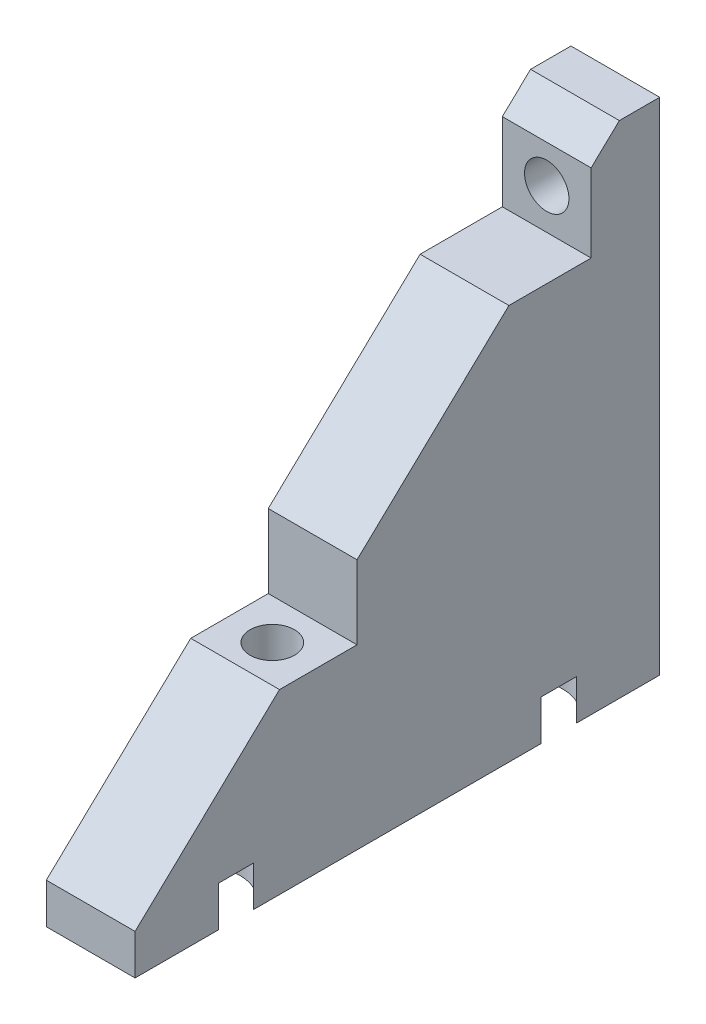
from build123d import *

# Parameters (mm, degrees)
SKETCH1_W           = 65
SKETCH1_H           = 57
BOSS_EXTRUDE1_DEPTH = 5
SKETCH2_W           = 65
SKETCH2_H           = 65
SKETCH2_R           = 2.75
SKETCH2_R_2         = 5
BOSS_EXTRUDE2_DEPTH = 5
SKETCH3_W           = 11
SKETCH3_H           = 60
BOSS_EXTRUDE7_DEPTH = 57
CUT_EXTRUDE2_DEPTH  = 165.705798319
SKETCH6_R           = 2.75
CUT_EXTRUDE3_DEPTH  = 89.911472826
SKETCH7_R           = 2.75
CUT_EXTRUDE4_DEPTH  = 160.515673211
CUT_EXTRUDE5_START  = 57
SKETCH8_W           = 11
SKETCH8_H           = 10
CUT_EXTRUDE5_DEPTH  = 40
CUT_EXTRUDE6_START  = 60
SKETCH9_W           = 11
SKETCH9_H           = 10
CUT_EXTRUDE6_DEPTH  = 56.5
SKETCH10_W          = 7
SKETCH10_H          = 62
SKETCH10_W_2        = 29
CUT_EXTRUDE7_DEPTH  = 160.515673211


with BuildPart() as part:
    # Sketch1 → Boss-Extrude1 (new body)
    with BuildSketch(Plane.XY):
        with Locations((0, -108.5)):
            Rectangle(SKETCH1_W, SKETCH1_H)
    extrude(amount=-BOSS_EXTRUDE1_DEPTH)

    # Sketch2 → Boss-Extrude2 (add)
    with BuildSketch(Plane.XZ.offset(137)):
        with Locations((0, 27.5)):
            Rectangle(SKETCH2_W, SKETCH2_H)
        with Locations(Location((20, 37.5, 0), (0, 0, 270))):
            Circle(SKETCH2_R, mode=Mode.SUBTRACT)
        with Locations(Location((21, 47.5, 0), (0, 0, 270))):
            Circle(SKETCH2_R_2, mode=Mode.SUBTRACT)
        with Locations(Location((-20, 47.5, 0), (0, 0, 270))):
            Circle(SKETCH2_R_2, mode=Mode.SUBTRACT)
        with Locations(Location((-20, 7.5, 0), (0, 0, 90))):
            Circle(SKETCH2_R_2, mode=Mode.SUBTRACT)
        with Locations(Location((21, 7.5, 0), (0, 0, 90))):
            Circle(SKETCH2_R_2, mode=Mode.SUBTRACT)
        with Locations(Location((-20, 37.5, 0), (0, 0, 90))):
            Circle(SKETCH2_R, mode=Mode.SUBTRACT)
    extrude(amount=BOSS_EXTRUDE2_DEPTH)

    # Sketch3 → Boss-Extrude7 (add)
    with BuildSketch(Plane(origin=(0, -137, 0), x_dir=(1, 0, 0), z_dir=(0, 1, 0))):
        with Locations((20, -30)):
            Rectangle(SKETCH3_W, SKETCH3_H)
        with Locations((-20, -30)):
            Rectangle(SKETCH3_W, SKETCH3_H)
    extrude(amount=BOSS_EXTRUDE7_DEPTH)

    # Sketch5 → Cut-Extrude2 (cut, through all)
    with BuildSketch(Plane(origin=(25.5, 0, 0), x_dir=(0, 0, -1), z_dir=(1, 0, 0))):
        Polygon((-60, -137), (0, -80), (-60, -80), align=None)
    extrude(amount=-CUT_EXTRUDE2_DEPTH, mode=Mode.SUBTRACT)

    # Sketch6 → Cut-Extrude3 (cut, through all)
    with BuildSketch(Plane.XZ.offset(137)):
        with Locations(Location((-20, 37.5, 0), (0, 0, 90))):
            Circle(SKETCH6_R)
        with Locations(Location((20, 37.5, 0), (0, 0, 90))):
            Circle(SKETCH6_R)
    extrude(amount=-CUT_EXTRUDE3_DEPTH, mode=Mode.SUBTRACT)

    # Sketch7 → Cut-Extrude4 (cut, through all)
    with BuildSketch(Plane.XY.offset(60)):
        with Locations((-20, -88)):
            Circle(SKETCH7_R)
        with Locations(Location((20, -88, 0), (0, 0, 270))):
            Circle(SKETCH7_R)
    extrude(amount=-CUT_EXTRUDE4_DEPTH, mode=Mode.SUBTRACT)

    # Sketch8 → Cut-Extrude5 (cut)
    with BuildSketch(Plane(origin=(0, -137, 0), x_dir=(1, 0, 0), z_dir=(0, 1, 0)).offset(CUT_EXTRUDE5_START)):
        with Locations((20, -37.5)):
            Rectangle(SKETCH8_W, SKETCH8_H)
        with Locations((-20, -37.5)):
            Rectangle(SKETCH8_W, SKETCH8_H)
    extrude(amount=-CUT_EXTRUDE5_DEPTH, mode=Mode.SUBTRACT)

    # Sketch9 → Cut-Extrude6 (cut)
    with BuildSketch(Plane.XY.offset(CUT_EXTRUDE6_START)):
        with Locations((-20, -88)):
            Rectangle(SKETCH9_W, SKETCH9_H)
        with Locations((20, -88)):
            Rectangle(SKETCH9_W, SKETCH9_H)
    extrude(amount=-CUT_EXTRUDE6_DEPTH, mode=Mode.SUBTRACT)

    # Sketch10 → Cut-Extrude7 (cut, through all)
    with BuildSketch(Plane.XY.offset(60)):
        with Locations((-29, -111)):
            Rectangle(SKETCH10_W, SKETCH10_H)
        with Locations((0, -111)):
            Rectangle(SKETCH10_W_2, SKETCH10_H)
        with Locations((29, -111)):
            Rectangle(SKETCH10_W, SKETCH10_H)
    extrude(amount=-CUT_EXTRUDE7_DEPTH, mode=Mode.SUBTRACT)


with BuildPart() as cut_extrude7_piece_1:
    # of the separate pieces the step leaves, piece 1, a body of its own (cut_extrude7_pieces)
    add(part.part.solids().sort_by_distance((25.5, -80, 0))[0])


with BuildPart() as cut_extrude7_piece_2:
    # of the separate pieces the step leaves, piece 2, a body of its own (cut_extrude7_pieces)
    add(part.part.solids().sort_by_distance((-14.5, -80, 0))[0])


solid = cut_extrude7_piece_1.part
